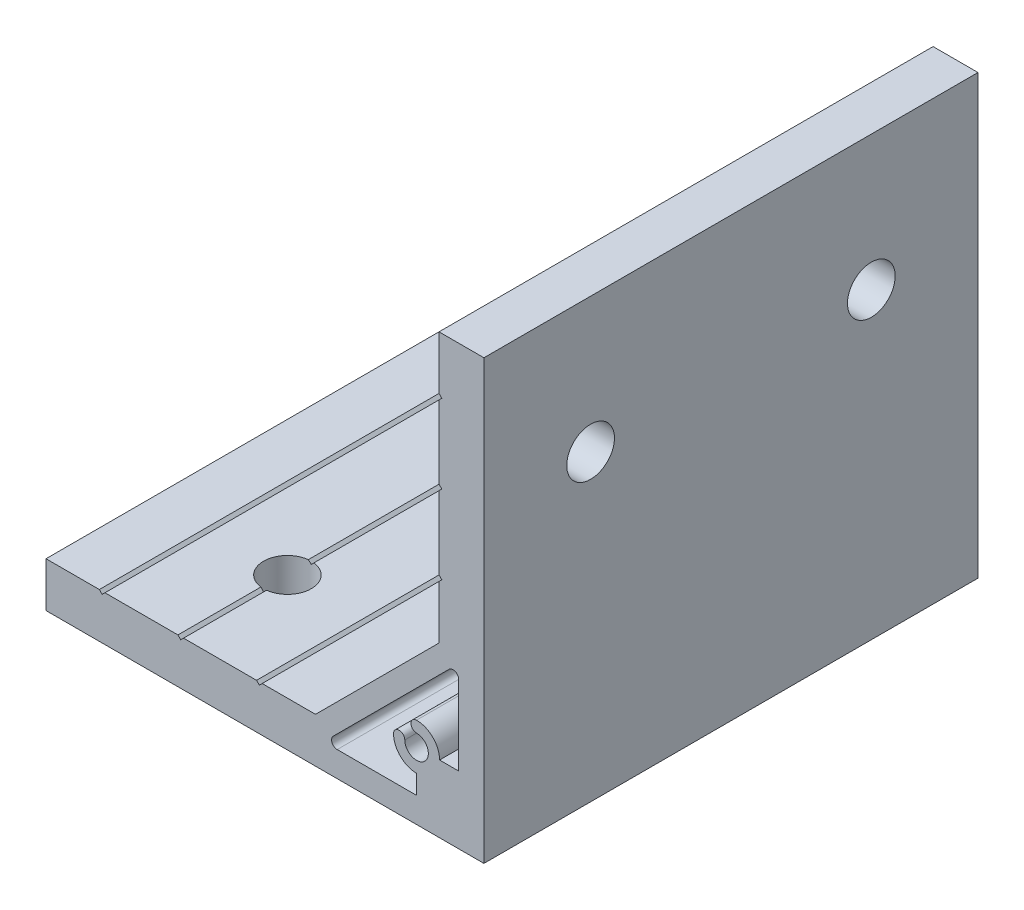
from build123d import *

# Parameters (mm, degrees)
EXTRUDE_1_DEPTH     = 44
SKETCH_2_R          = 4.25
CUT_EXTRUDE_1_DEPTH = 9
SKETCH_3_R          = 4.25
CUT_EXTRUDE_2_DEPTH = 9


with BuildPart() as part:
    # Эскиз1 → Бобышка-Вытянуть1 (new body, symmetric)
    with BuildSketch(Plane.XY):
        Polygon((-78, 0), (0, 0), (0, 78), (-8, 78), (-8, 68.5), (-7.5, 68), (-8, 67.5), (-8, 54.5), (-7.5, 54), (-8, 53.5), (-8, 40.5), (-7.5, 40), (-8, 39.5), (-8, 30), (-30, 8), (-39.5, 8), (-40, 7.5), (-40.5, 8), (-53.5, 8), (-54, 7.5), (-54.5, 8), (-67.5, 8), (-68, 7.5), (-68.5, 8), (-78, 8), align=None)
        with BuildLine():
            Line((-4.5, 12), (-4.5, 26.136038969))
            ThreePointArc((-4.5, 26.136038969), (-5.117316568, 27.059918502), (-6.207106781, 26.843145751))
            Line((-6.207106781, 26.843145751), (-26.843145751, 6.207106781))
            ThreePointArc((-26.843145751, 6.207106781), (-27.059918502, 5.117316568), (-26.136038969, 4.5))
            Line((-26.136038969, 4.5), (-12, 4.5))
            Line((-12, 4.5), (-12, 7.9))
            ThreePointArc((-12, 7.9), (-14.899137803, 9.100862197), (-16.1, 12))
            ThreePointArc((-16.1, 12), (-15.1, 13), (-14.1, 12))
            ThreePointArc((-14.1, 12), (-10.51507576, 10.51507576), (-12, 14.1))
            ThreePointArc((-12, 14.1), (-13, 15.1), (-12, 16.1))
            ThreePointArc((-12, 16.1), (-9.100862197, 14.899137803), (-7.9, 12))
            Line((-7.9, 12), (-4.5, 12))
        make_face(mode=Mode.SUBTRACT)
    extrude(amount=EXTRUDE_1_DEPTH, both=True)

    # Эскиз2 → Вырез-Вытянуть1 (cut, through all)
    with BuildSketch(Plane.ZY.offset(8)):
        with Locations(Location((-25, 54, 0), (0, 0, 270))):  # turned: the seam where the file's is
            Circle(SKETCH_2_R)
        with Locations(Location((25, 54, 0), (0, 0, 270))):  # turned: the seam where the file's is
            Circle(SKETCH_2_R)
    extrude(amount=-CUT_EXTRUDE_1_DEPTH, mode=Mode.SUBTRACT)

    # Эскиз3 → Вырез-Вытянуть2 (cut, through all)
    with BuildSketch(Plane(origin=(0, 8, 0), x_dir=(1, 0, 0), z_dir=(0, 1, 0))):
        with Locations(Location((-54, -25, 0), (0, 0, 180))):  # turned: the seam where the file's is
            Circle(SKETCH_3_R)
        with Locations(Location((-54, 25, 0), (0, 0, 180))):  # turned: the seam where the file's is
            Circle(SKETCH_3_R)
    extrude(amount=-CUT_EXTRUDE_2_DEPTH, mode=Mode.SUBTRACT)


solid = part.part
